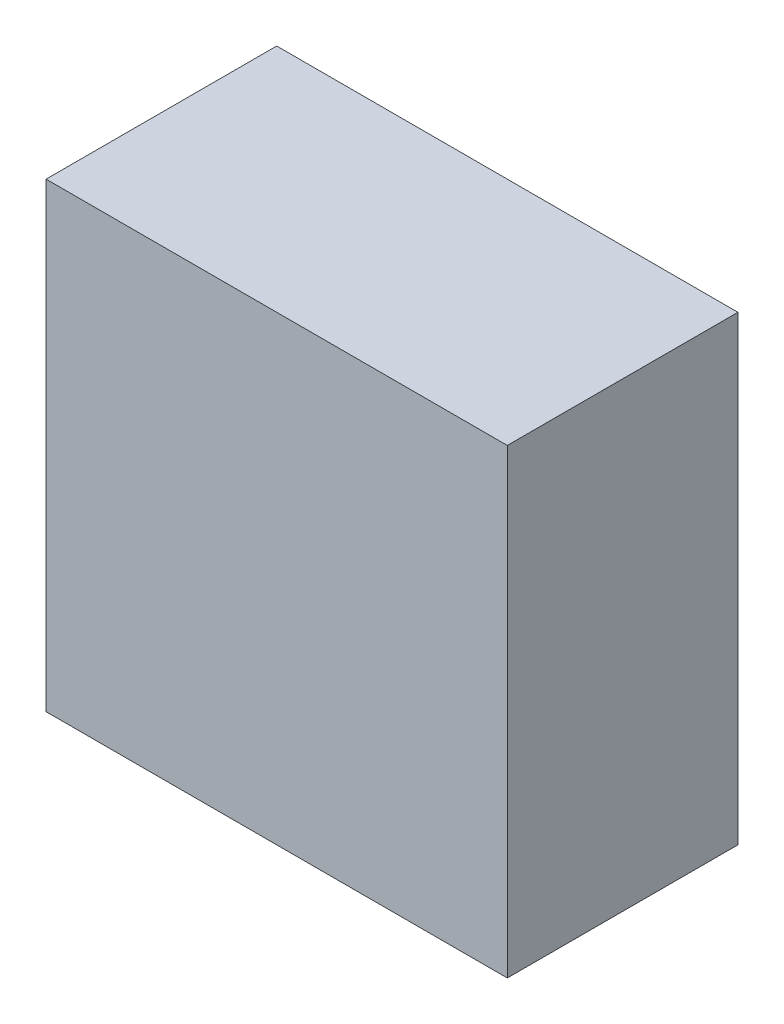
from build123d import *

# Parameters (mm, degrees)
SKETCH_1_W      = 60
SKETCH_1_H      = 60
EXTRUDE_1_DEPTH = 30


with BuildPart() as part:
    # 草图1 → 凸台-拉伸1 (new body)
    with BuildSketch(Plane.XY):
        Rectangle(SKETCH_1_W, SKETCH_1_H)
    extrude(amount=EXTRUDE_1_DEPTH)


solid = part.part
